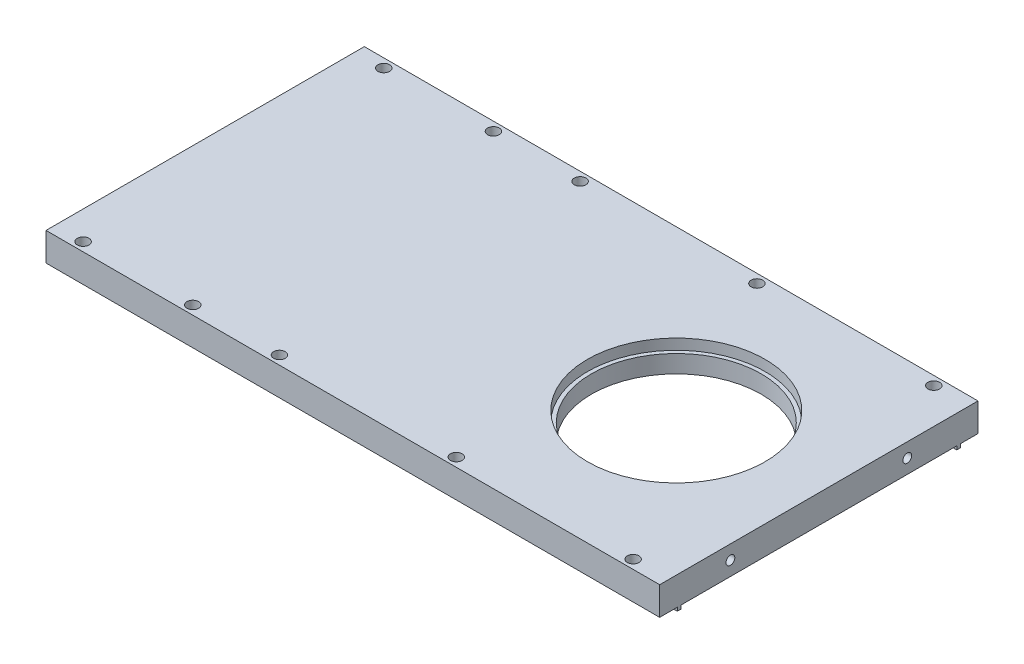
from build123d import *

# Parameters (mm, degrees)
BOSS_EXTRUDE1_DEPTH   = 90
SKETCH2_R             = 24
CUT_EXTRUDE1_DEPTH    = 9
SKETCH3_R             = 25.1
CUT_EXTRUDE2_DEPTH    = 3
SKETCH4_W             = 143.5
SKETCH4_H             = 1
BOSS_EXTRUDE2_DEPTH   = 1
SKETCH5_W             = 10
SKETCH5_H             = 1
BOSS_EXTRUDE3_DEPTH   = 2
SKETCH6_R             = 1.65
CUT_EXTRUDE3_DEPTH    = 39
M3_TAPPED_HOLE1_D     = 2.5
M3_TAPPED_HOLE1_DEPTH = 8.5
M3_TAPPED_HOLE1_TIP   = 0.751075774
SKETCH_1_W            = 53.5
SKETCH_1_H            = 19
CUT_EXTRUDE_1_DEPTH   = 90


with BuildPart() as part:
    # Sketch1 → Boss-Extrude1 (new body)
    with BuildSketch(Plane.XY):
        Polygon((0, 0), (0, 5), (53.5, 5), (53.5, -14), (217, -14), (217, -22), (43.5, -22), (43.5, 0), align=None)
    extrude(amount=BOSS_EXTRUDE1_DEPTH)

    # Sketch2 → Cut-Extrude1 (cut, through all)
    with BuildSketch(Plane(origin=(0, -14, 0), x_dir=(1, 0, 0), z_dir=(0, 1, 0))):
        with Locations((176.7, -45)):
            Circle(SKETCH2_R)
    extrude(amount=-CUT_EXTRUDE1_DEPTH, mode=Mode.SUBTRACT)

    # Sketch3 → Cut-Extrude2 (cut)
    with BuildSketch(Plane(origin=(0, -14, 0), x_dir=(1, 0, 0), z_dir=(0, 1, 0))):
        with Locations((176.7, -45)):
            Circle(SKETCH3_R)
    extrude(amount=-CUT_EXTRUDE2_DEPTH, mode=Mode.SUBTRACT)

    # Sketch4 → Boss-Extrude2 (add)
    with BuildSketch(Plane.XZ.offset(22)):
        with Locations((145.25, 84.5)):
            Rectangle(SKETCH4_W, SKETCH4_H)
        with Locations((145.25, 5.5)):
            Rectangle(SKETCH4_W, SKETCH4_H)
    extrude(amount=BOSS_EXTRUDE2_DEPTH)

    # Sketch5 → Boss-Extrude3 (add)
    with BuildSketch(Plane.XZ):
        with Locations((28.5, 84.5)):
            Rectangle(SKETCH5_W, SKETCH5_H)
        with Locations((28.5, 5.5)):
            Rectangle(SKETCH5_W, SKETCH5_H)
    extrude(amount=BOSS_EXTRUDE3_DEPTH)

    # Sketch6 → Cut-Extrude3 (cut, through all)
    with BuildSketch(Plane(origin=(0, 15, 0), x_dir=(1, 0, 0), z_dir=(0, 1, 0))):
        with Locations((51.5, -2.5)):
            Circle(SKETCH6_R)
        with Locations((82.5, -2.5)):
            Circle(SKETCH6_R)
        with Locations((51.5, -87.5)):
            Circle(SKETCH6_R)
        with Locations((82.5, -87.5)):
            Circle(SKETCH6_R)
        with Locations((107, -87.5)):
            Circle(SKETCH6_R)
        with Locations((157, -87.5)):
            Circle(SKETCH6_R)
        with Locations((207, -87.5)):
            Circle(SKETCH6_R)
        with Locations((107, -2.5)):
            Circle(SKETCH6_R)
        with Locations((157, -2.5)):
            Circle(SKETCH6_R)
        with Locations((207, -2.5)):
            Circle(SKETCH6_R)
    extrude(amount=-CUT_EXTRUDE3_DEPTH, mode=Mode.SUBTRACT)

    # M3 Tapped Hole1
    with Locations(Plane(origin=(217, 0, 0), x_dir=(0, 0, -1), z_dir=(1, 0, 0))):
        with Locations((-70, -18), (-20, -18)):
            Hole(M3_TAPPED_HOLE1_D / 2, depth=M3_TAPPED_HOLE1_DEPTH)
            with Locations((0, 0, -(M3_TAPPED_HOLE1_DEPTH + M3_TAPPED_HOLE1_TIP / 2))):  # 118° drill point
                Cone(0, M3_TAPPED_HOLE1_D / 2, M3_TAPPED_HOLE1_TIP, mode=Mode.SUBTRACT)

    # 草图1 → 切除-拉伸1 (cut)
    with BuildSketch(Plane.XY.offset(90)):
        with Locations((26.75, -4.5)):
            Rectangle(SKETCH_1_W, SKETCH_1_H)
    extrude(amount=-CUT_EXTRUDE_1_DEPTH, mode=Mode.SUBTRACT)


solid = part.part
